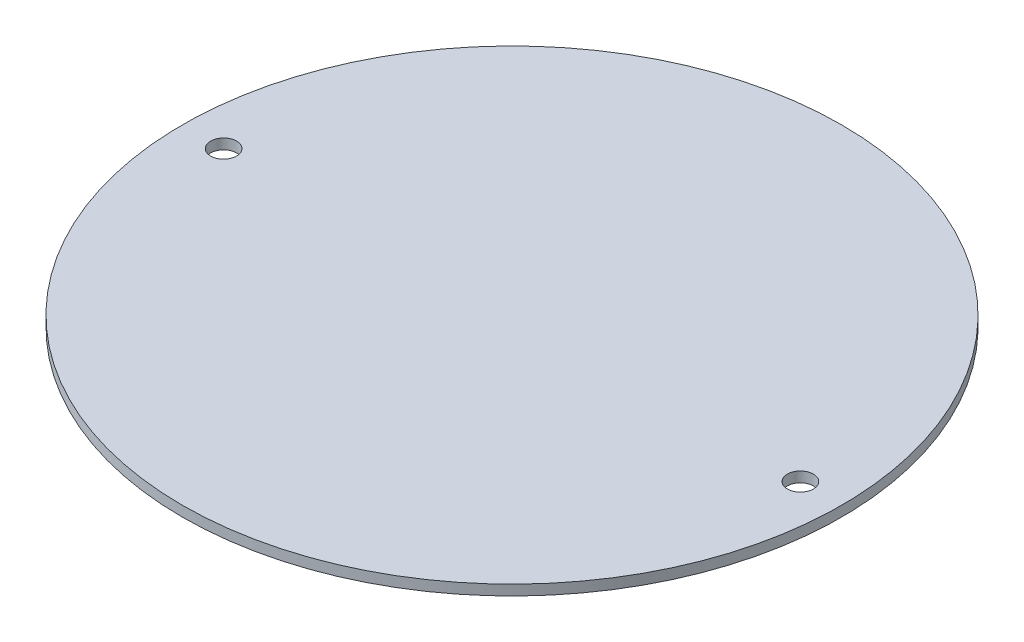
from build123d import *

# Parameters (mm, degrees)
SKETCH1_R           = 25.4
SKETCH1_R_2         = 1
BOSS_EXTRUDE1_DEPTH = 0.396875


with BuildPart() as part:
    # Sketch1 → Boss-Extrude1 (new body, symmetric)
    with BuildSketch(Plane(origin=(0, 0, 0), x_dir=(1, 0, 0), z_dir=(0, 1, 0))):
        Circle(SKETCH1_R)
        with Locations((-22.225, 0)):
            Circle(SKETCH1_R_2, mode=Mode.SUBTRACT)
        with Locations((22.225, 0)):
            Circle(SKETCH1_R_2, mode=Mode.SUBTRACT)
    extrude(amount=BOSS_EXTRUDE1_DEPTH, both=True)


solid = part.part
